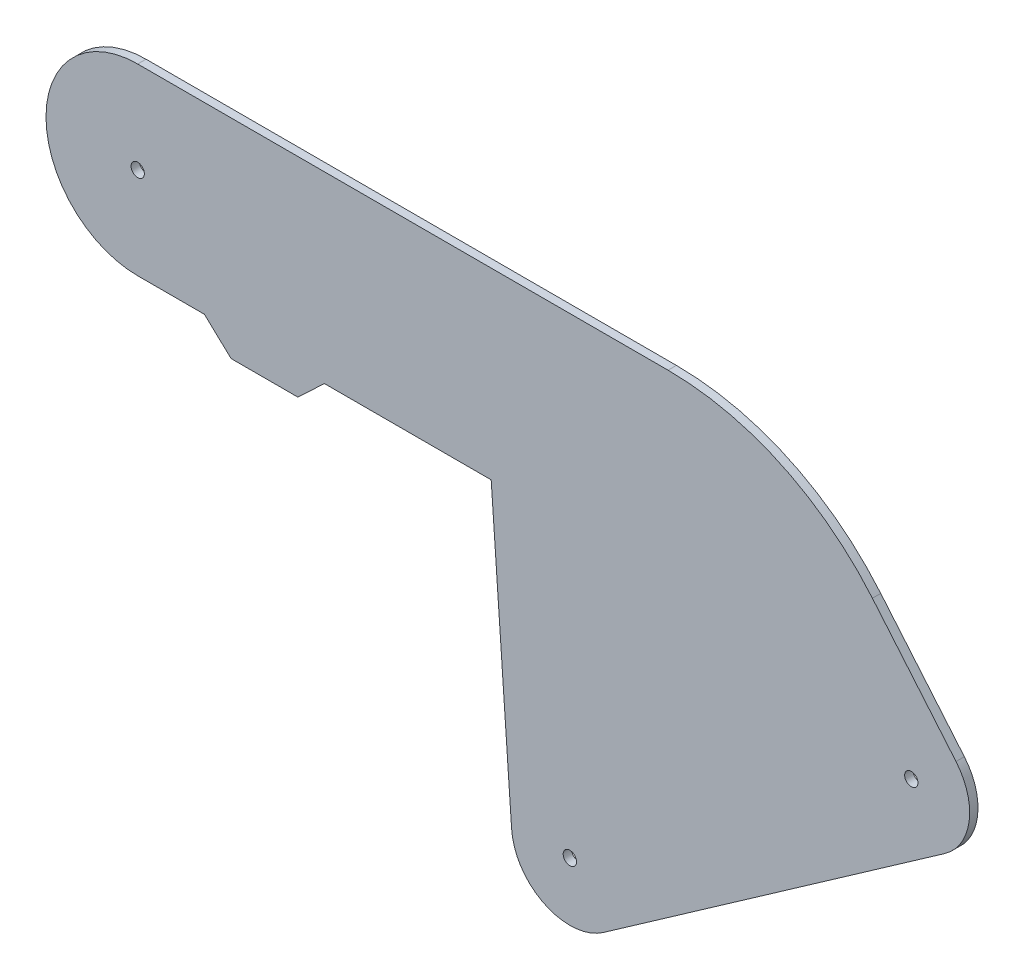
from build123d import *

# Parameters (mm, degrees)
SKETCH1_R           = 2.54
BOSS_EXTRUDE1_DEPTH = 3.175


with BuildPart() as part:
    # Sketch1 → Boss-Extrude1 (new body)
    with BuildSketch(Plane.XY):
        with BuildLine():
            Line((134.62, 180.975), (142.401211704, 69.698488351))
            ThreePointArc((142.401211704, 69.698488351), (155.003963594, 51.188868036), (177.319809019, 53.043171796))
            Line((177.319809019, 53.043171796), (307.36019605, 144.098431067))
            ThreePointArc((307.36019605, 144.098431067), (316.647321796, 159.403140629), (311.6377975, 176.590039876))
            Line((311.6377975, 176.590039876), (279.800527192, 214.532221144))
            ThreePointArc((279.800527192, 214.532221144), (244.908427164, 241.305871163), (201.970411771, 250.825))
            Line((201.970411771, 250.825), (0, 250.825))
            ThreePointArc((0, 250.825), (-34.925, 215.9), (0, 180.975))
            Line((0, 180.975), (25.4, 180.975))
            Line((25.4, 180.975), (35.56, 171.45))
            Line((35.56, 171.45), (60.96, 171.45))
            Line((60.96, 171.45), (71.12, 180.975))
            Line((71.12, 180.975), (134.62, 180.975))
        make_face()
        with Locations((294.612459752, 162.304085251)):
            Circle(SKETCH1_R, mode=Mode.SUBTRACT)
        with Locations((164.572072721, 71.24882598)):
            Circle(SKETCH1_R, mode=Mode.SUBTRACT)
        with Locations((0, 215.9)):
            Circle(SKETCH1_R, mode=Mode.SUBTRACT)
    extrude(amount=BOSS_EXTRUDE1_DEPTH)


solid = part.part
